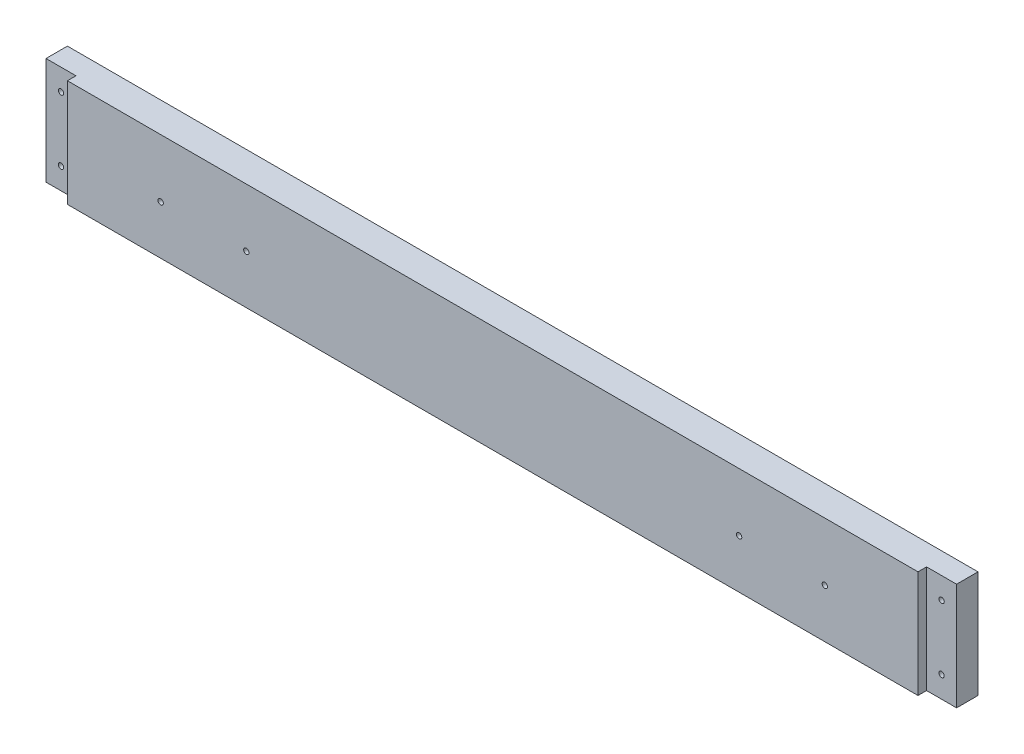
from build123d import *

# Parameters (mm, degrees)
SKETCH2_W          = 539.75
SKETCH2_H          = 63.5
EXTRUDE1_DEPTH     = 17.78
SKETCH3_W          = 17.78
SKETCH3_H          = 63.5
CUT_EXTRUDE1_DEPTH = 5.08
SKETCH4_R          = 1.5875
CUT_EXTRUDE2_DEPTH = 17.78
SKETCH5_R          = 1.5875
CUT_EXTRUDE3_DEPTH = 17.78


with BuildPart() as part:
    # Sketch2 → Extrude1 (new body)
    with BuildSketch(Plane.XY):
        with Locations((11108.266666666, -5688.0125)):
            Rectangle(SKETCH2_W, SKETCH2_H)
    extrude(amount=-EXTRUDE1_DEPTH)

    # Sketch3 → Cut-Extrude1 (cut)
    with BuildSketch(Plane.XY):
        with Locations((11369.251666666, -5688.0125)):
            Rectangle(SKETCH3_W, SKETCH3_H)
        with Locations((10847.281666666, -5688.0125)):
            Rectangle(SKETCH3_W, SKETCH3_H)
    extrude(amount=-CUT_EXTRUDE1_DEPTH, mode=Mode.SUBTRACT)

    # Sketch4 → Cut-Extrude2 (cut)
    with BuildSketch(Plane.XY):
        with Locations((10847.281666666, -5668.9625)):
            Circle(SKETCH4_R)
        with Locations((10847.281666666, -5707.0625)):
            Circle(SKETCH4_R)
        with Locations((11369.251666666, -5707.0625)):
            Circle(SKETCH4_R)
        with Locations((11369.251666666, -5668.9625)):
            Circle(SKETCH4_R)
    extrude(amount=-CUT_EXTRUDE2_DEPTH, mode=Mode.SUBTRACT)

    # Sketch5 → Cut-Extrude3 (cut)
    with BuildSketch(Plane(origin=(0, 0, -17.78), x_dir=(-1, 0, 0), z_dir=(0, 0, -1))):
        with Locations((-10911.416666665, -5690.78745)):
            Circle(SKETCH5_R)
        with Locations((-10962.216666665, -5690.78745)):
            Circle(SKETCH5_R)
        with Locations((-11254.316666665, -5690.78745)):
            Circle(SKETCH5_R)
        with Locations((-11305.116666665, -5690.78745)):
            Circle(SKETCH5_R)
    extrude(amount=-CUT_EXTRUDE3_DEPTH, mode=Mode.SUBTRACT)


solid = part.part
